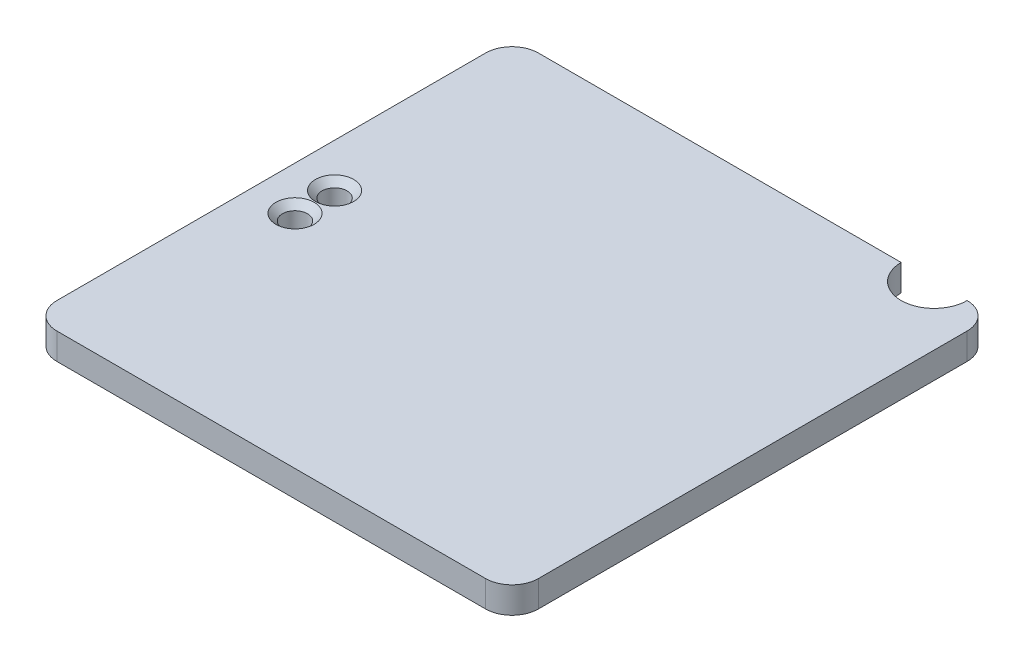
from build123d import *

# Parameters (mm, degrees)
BOSS_EXTRUDE1_DEPTH = 7
SKETCH2_W           = 44.9
SKETCH2_H           = 67
CUT_EXTRUDE1_DEPTH  = 10
SKETCH3_R           = 1.9
CUT_EXTRUDE2_DEPTH  = 15
CHAMFER1_SIZE       = 1
SKETCH2_3_W         = 2
SKETCH2_3_H         = 15
CUT_EXTRUDE5_DEPTH  = 4
SKETCH7_W           = 2
SKETCH7_H           = 15
BOSS_EXTRUDE2_DEPTH = 1
CUT_EXTRUDE7_DEPTH  = 15
SKETCH11_W          = 7.1
SKETCH11_H          = 26
CUT_EXTRUDE9_DEPTH  = 6
CUT_EXTRUDE10_DEPTH = 10
SKETCH15_W          = 7.1
SKETCH15_H          = 1.45
BOSS_EXTRUDE3_DEPTH = 1


with BuildPart() as part:
    # Sketch1 → Boss-Extrude1 (new body, symmetric)
    with BuildSketch(Plane(origin=(0, 0, 0), x_dir=(1, 0, 0), z_dir=(0, 1, 0))):
        with BuildLine():
            ThreePointArc((-36.5, -32.5), (-36.358942749, -33.552882169), (-35.945719569, -34.531506006))
            Line((-35.945719569, -34.531506006), (0, 1.414213562))
            Line((0, 1.414213562), (-34.531506006, 35.945719569))
            ThreePointArc((-34.531506006, 35.945719569), (-35.973184708, 34.484184464), (-36.5, 32.5))
            Line((-36.5, 32.5), (-36.5, -32.5))
        make_face()
        with BuildLine():
            Line((-34.531506006, 35.945719569), (0, 1.414213562))
            Line((0, 1.414213562), (34.531506006, 35.945719569))
            ThreePointArc((34.531506006, 35.945719569), (33.552882169, 36.358942749), (32.5, 36.5))
            Line((32.5, 36.5), (-32.5, 36.5))
            ThreePointArc((-32.5, 36.5), (-33.552882169, 36.358942749), (-34.531506006, 35.945719569))
        make_face()
        with BuildLine():
            Line((0, 1.414213562), (35.945719569, -34.531506006))
            ThreePointArc((35.945719569, -34.531506006), (36.358942749, -33.552882169), (36.5, -32.5))
            Line((36.5, -32.5), (36.5, 32.5))
            ThreePointArc((36.5, 32.5), (35.973184708, 34.484184464), (34.531506006, 35.945719569))
            Line((34.531506006, 35.945719569), (0, 1.414213562))
        make_face()
        with BuildLine():
            ThreePointArc((-35.945719569, -34.531506006), (-34.484184464, -35.973184708), (-32.5, -36.5))
            Line((-32.5, -36.5), (32.5, -36.5))
            ThreePointArc((32.5, -36.5), (34.484184464, -35.973184708), (35.945719569, -34.531506006))
            Line((35.945719569, -34.531506006), (0, 1.414213562))
            Line((0, 1.414213562), (-35.945719569, -34.531506006))
        make_face()
    extrude(amount=BOSS_EXTRUDE1_DEPTH, both=True)

    # Sketch2 → Cut-Extrude1 (cut)
    with BuildSketch(Plane.XZ.offset(7)):
        with Locations((-3.95, 0)):
            Rectangle(SKETCH2_W, SKETCH2_H)
        with BuildLine():
            Line((18.5, 33.5), (18.5, -33.5))
            Line((18.5, -33.5), (18.5, -36.5))
            Line((18.5, -36.5), (32.5, -36.5))
            ThreePointArc((32.5, -36.5), (35.328427125, -35.328427125), (36.5, -32.5))
            Line((36.5, -32.5), (36.5, 32.5))
            ThreePointArc((36.5, 32.5), (35.328427125, 35.328427125), (32.5, 36.5))
            Line((32.5, 36.5), (18.5, 36.5))
            Line((18.5, 36.5), (18.5, 33.5))
        make_face()
    extrude(amount=-CUT_EXTRUDE1_DEPTH, mode=Mode.SUBTRACT)

    # Sketch3 → Cut-Extrude2 (cut, through all)
    with BuildSketch(Plane.XZ.offset(7)):
        with Locations((-29.9, 3)):
            Circle(SKETCH3_R)
        with Locations((-29.9, -3)):
            Circle(SKETCH3_R)
    extrude(amount=-CUT_EXTRUDE2_DEPTH, mode=Mode.SUBTRACT)

    # Chamfer1
    chamfer1_edges = [part.edges().sort_by_distance(p)[0] for p in [
        (-31.8, 7, 3),
        (-31.8, 7, -3),
    ]]
    chamfer(chamfer1_edges, length=CHAMFER1_SIZE)

    # Sketch2_3 → Cut-Extrude5 (cut)
    with BuildSketch(Plane.XZ.offset(7)):
        Polygon((-33.5, -7.5), (-33.5, -33.5), (-26.4, -33.5), (-26.4, 33.5), (-33.5, 33.5), (-33.5, 7.5), align=None)
        with Locations((-34.5, 0)):
            Rectangle(SKETCH2_3_W, SKETCH2_3_H)
    extrude(amount=-CUT_EXTRUDE5_DEPTH, mode=Mode.SUBTRACT)

    # Sketch7 → Boss-Extrude2 (add)
    with BuildSketch(Plane.XZ.offset(3)):
        with Locations((-34.5, 0)):
            Rectangle(SKETCH7_W, SKETCH7_H)
    extrude(amount=BOSS_EXTRUDE2_DEPTH)

    # Sketch9 → Cut-Extrude7 (cut, through all)
    with BuildSketch(Plane(origin=(0, 7, 0), x_dir=(1, 0, 0), z_dir=(0, 1, 0))):
        with BuildLine():
            Line((32.5, 36.5), (22.5, 36.5))
            ThreePointArc((22.5, 36.5), (27.5, 31.5), (32.5, 36.5))
        make_face()
    extrude(amount=-CUT_EXTRUDE7_DEPTH, mode=Mode.SUBTRACT)

    # Sketch11 → Cut-Extrude9 (cut)
    with BuildSketch(Plane.XZ.offset(3)):
        with Locations((-29.95, 20.5)):
            Rectangle(SKETCH11_W, SKETCH11_H)
        with Locations((-29.95, -20.5)):
            Rectangle(SKETCH11_W, SKETCH11_H)
    extrude(amount=-CUT_EXTRUDE9_DEPTH, mode=Mode.SUBTRACT)

    # Sketch13 → Cut-Extrude10 (cut)
    with BuildSketch(Plane.XZ.offset(7)):
        with BuildLine():
            Line((-32.5, -36.5), (18.5, -36.5))
            Line((18.5, -36.5), (18.5, -33.5))
            Line((18.5, -33.5), (-33.5, -33.5))
            Line((-33.5, -33.5), (-33.5, -7.5))
            Line((-33.5, -7.5), (-35.5, -7.5))
            Line((-35.5, -7.5), (-35.5, 7.5))
            Line((-35.5, 7.5), (-33.5, 7.5))
            Line((-33.5, 7.5), (-33.5, 33.5))
            Line((-33.5, 33.5), (18.5, 33.5))
            Line((18.5, 33.5), (18.5, 36.5))
            Line((18.5, 36.5), (-32.5, 36.5))
            ThreePointArc((-32.5, 36.5), (-35.328427125, 35.328427125), (-36.5, 32.5))
            Line((-36.5, 32.5), (-36.5, -32.5))
            ThreePointArc((-36.5, -32.5), (-35.328427125, -35.328427125), (-32.5, -36.5))
        make_face()
    extrude(amount=-CUT_EXTRUDE10_DEPTH, mode=Mode.SUBTRACT)

    # Sketch15 → Boss-Extrude3 (add)
    with BuildSketch(Plane.XZ.offset(3)):
        with Locations((-29.95, -6.775)):
            Rectangle(SKETCH15_W, SKETCH15_H)
    extrude(amount=BOSS_EXTRUDE3_DEPTH)


solid = part.part
